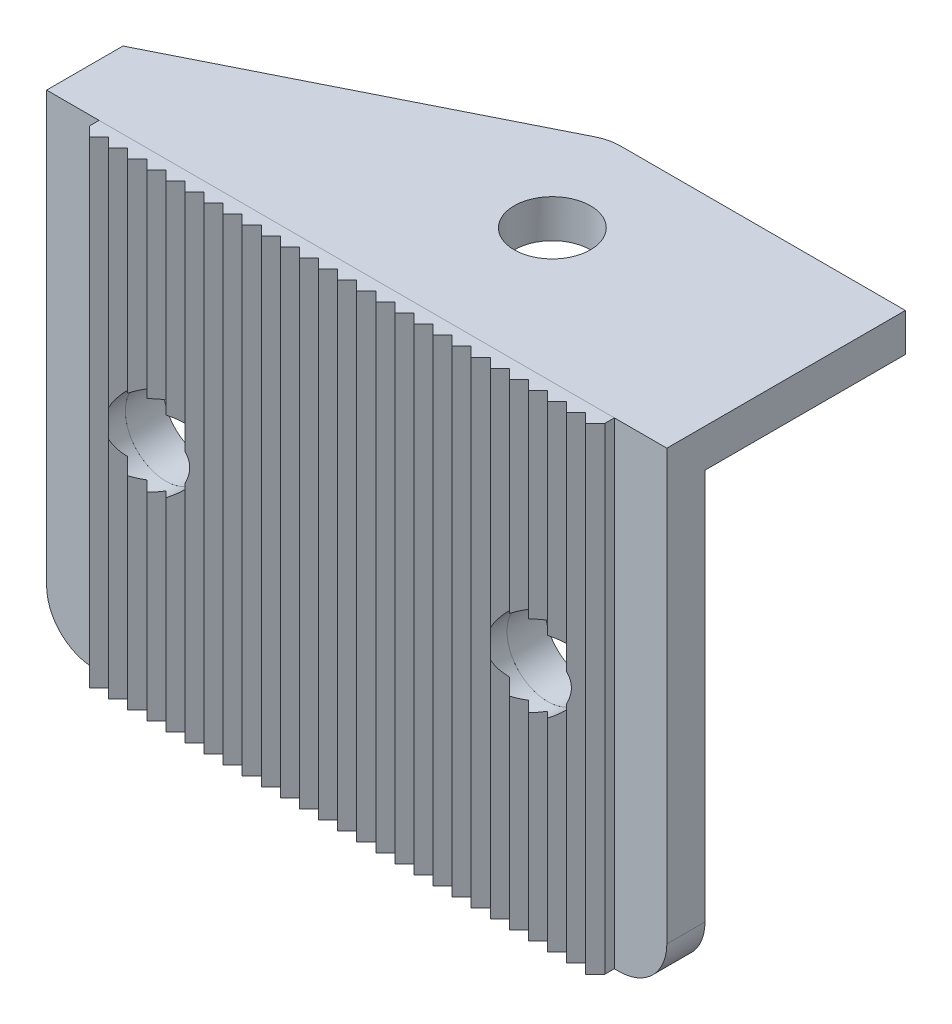
from build123d import *

# Parameters (mm, degrees)
BOSS_EXTRU_1_DEPTH      = 4
BOSS_EXTRU_2_DEPTH      = 4
CONG_1_R                = 5
ESQUISSE4_R             = 4.25
ENL_V_MAT_EXTRU_1_DEPTH = 4
ESQUISSE5_R             = 4
ENL_V_MAT_EXTRU_2_DEPTH = 4
BOSS_EXTRU_3_DEPTH      = 50
ESQUISSE7_R             = 4.25
ENL_V_MAT_EXTRU_3_DEPTH = 3


with BuildPart() as part:
    # Esquisse1 → Boss.-Extru.1 (new body)
    with BuildSketch(Plane.XY):
        with BuildLine():
            Line((-32.5, 25), (32.5, 25))
            Line((32.5, 25), (32.5, -20))
            ThreePointArc((32.5, -20), (31.035533906, -23.535533906), (27.5, -25))
            Line((27.5, -25), (-27.5, -25))
            ThreePointArc((-27.5, -25), (-31.035533906, -23.535533906), (-32.5, -20))
            Line((-32.5, -20), (-32.5, 25))
        make_face()
    extrude(amount=BOSS_EXTRU_1_DEPTH)

    # Esquisse3 → Boss.-Extru.2 (add)
    with BuildSketch(Plane(origin=(0, 25, 0), x_dir=(1, 0, 0), z_dir=(0, 1, 0))):
        Polygon((-32.5, 0), (-32.5, 4), (1.5, 21), (32.5, 21), (32.5, 0), align=None)
    extrude(amount=-BOSS_EXTRU_2_DEPTH)

    # Congé1
    cong_1_edges = [part.edges().sort_by_distance(p)[0] for p in [
        (1.5, 23, -21),
    ]]
    fillet(cong_1_edges, radius=CONG_1_R)

    # Esquisse4 → Enlèv. mat.-Extru.1 (cut)
    with BuildSketch(Plane.XY.offset(4)):
        with Locations((-20, 0)):
            Circle(ESQUISSE4_R)
        with Locations((20, 0)):
            Circle(ESQUISSE4_R)
    extrude(amount=-ENL_V_MAT_EXTRU_1_DEPTH, mode=Mode.SUBTRACT)

    # Esquisse5 → Enlèv. mat.-Extru.2 (cut)
    with BuildSketch(Plane(origin=(0, 25, 0), x_dir=(1, 0, 0), z_dir=(0, 1, 0))):
        with Locations((6.5, 10)):
            Circle(ESQUISSE5_R)
    extrude(amount=-ENL_V_MAT_EXTRU_2_DEPTH, mode=Mode.SUBTRACT)


with BuildPart() as body_2:
    # Esquisse6 → Boss.-Extru.3 (new body)
    with BuildSketch(Plane(origin=(-7.5, -25, 0), x_dir=(0, 0, 1), z_dir=(0, 1, 0))):
        Polygon((4, -19.5), (5, -19.5), (6, -18.5), (5, -17.5), (6, -16.5), (5, -15.5), (6, -14.5), (5, -13.5), (6, -12.5), (5, -11.5), (6, -10.5), (5, -9.5), (6, -8.5), (5, -7.5), (6, -6.5), (5, -5.5), (6, -4.5), (5, -3.5), (6, -2.5), (5, -1.5), (6, -0.5), (5, 0.5), (6, 1.5), (5, 2.5), (6, 3.5), (5, 4.5), (6, 5.5), (5, 6.5), (6, 7.5), (5, 8.5), (6, 9.5), (5, 10.5), (6, 11.5), (5, 12.5), (6, 13.5), (5, 14.5), (6, 15.5), (5, 16.5), (6, 17.5), (5, 18.5), (6, 19.5), (5, 20.5), (6, 21.5), (5, 22.5), (6, 23.5), (5, 24.5), (6, 25.5), (5, 26.5), (6, 27.5), (5, 28.5), (6, 29.5), (5, 30.5), (6, 31.5), (5, 32.5), (6, 33.5), (5, 34.5), (4, 34.5), align=None)
    extrude(amount=BOSS_EXTRU_3_DEPTH)

    # Esquisse7 → Enlèv. mat.-Extru.3 (cut, through all)
    with BuildSketch(Plane(origin=(0, 0, 4), x_dir=(-1, 0, 0), z_dir=(0, 0, -1))):
        with Locations((-20, 0)):
            Circle(ESQUISSE7_R)
        with Locations((20, 0)):
            Circle(ESQUISSE7_R)
    extrude(amount=-ENL_V_MAT_EXTRU_3_DEPTH, mode=Mode.SUBTRACT)


solid = Compound([part.part, body_2.part])
